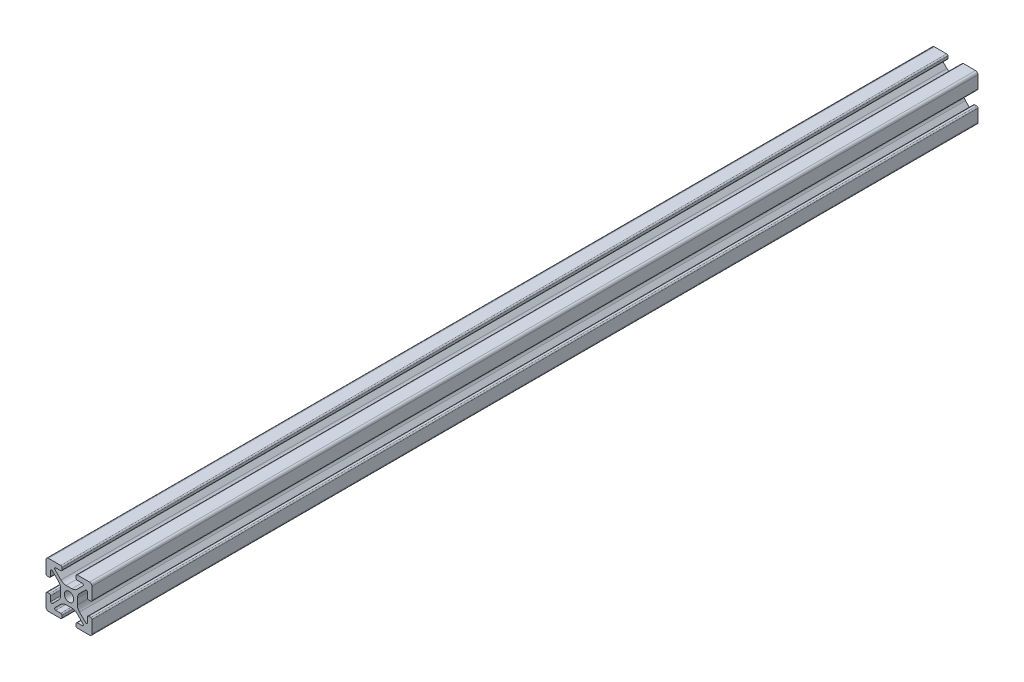
from build123d import *

# Parameters (mm, degrees)
SKETCH2_R           = 2.05
BOSS_EXTRUDE2_DEPTH = 385


with BuildPart() as part:
    # Sketch2 → Boss-Extrude2 (new body)
    with BuildSketch(Plane.XY):
        with BuildLine():
            Line((-3.642230561, 1.287773026), (-3.642230561, -1.287773026))
            ThreePointArc((-3.642230561, -1.287773026), (-3.87999308, -2.483085929), (-4.55708345, -3.496423279))
            Line((-4.55708345, -3.496423279), (-7.182004606, -6.121344434))
            ThreePointArc((-7.182004606, -6.121344434), (-7.704200045, -6.225215565), (-8, -5.782519648))
            Line((-8, -5.782519648), (-8, -3.622007668))
            ThreePointArc((-8, -3.622007668), (-8.161974206, -3.230967343), (-8.553014531, -3.068993137))
            Line((-8.553014531, -3.068993137), (-9.443284204, -3.068993137))
            ThreePointArc((-9.443284204, -3.068993137), (-9.836715763, -3.229656566), (-10, -3.622007668))
            Line((-10, -3.622007668), (-10, -8.939033256))
            ThreePointArc((-10, -8.939033256), (-9.689250035, -9.689250035), (-8.939033256, -10))
            Line((-8.939033256, -10), (-3.622007668, -10))
            ThreePointArc((-3.622007668, -10), (-3.229656566, -9.836715763), (-3.068993137, -9.443284204))
            Line((-3.068993137, -9.443284204), (-3.068993137, -8.553014531))
            ThreePointArc((-3.068993137, -8.553014531), (-3.230967343, -8.161974206), (-3.622007668, -8))
            Line((-3.622007668, -8), (-5.782519648, -8))
            ThreePointArc((-5.782519648, -8), (-6.225215565, -7.704200045), (-6.121344434, -7.182004606))
            Line((-6.121344434, -7.182004606), (-3.496423279, -4.55708345))
            ThreePointArc((-3.496423279, -4.55708345), (-2.483085929, -3.87999308), (-1.287773026, -3.642230561))
            Line((-1.287773026, -3.642230561), (1.287773026, -3.642230561))
            ThreePointArc((1.287773026, -3.642230561), (2.483085929, -3.87999308), (3.496423279, -4.55708345))
            Line((3.496423279, -4.55708345), (6.121344434, -7.182004606))
            ThreePointArc((6.121344434, -7.182004606), (6.225215565, -7.704200045), (5.782519648, -8))
            Line((5.782519648, -8), (3.622007668, -8))
            ThreePointArc((3.622007668, -8), (3.230967343, -8.161974206), (3.068993137, -8.553014531))
            Line((3.068993137, -8.553014531), (3.068993137, -9.443284204))
            ThreePointArc((3.068993137, -9.443284204), (3.229656566, -9.836715763), (3.622007668, -10))
            Line((3.622007668, -10), (8.939033256, -10))
            ThreePointArc((8.939033256, -10), (9.689250035, -9.689250035), (10, -8.939033256))
            Line((10, -8.939033256), (10, -3.622007668))
            ThreePointArc((10, -3.622007668), (9.836715763, -3.229656566), (9.443284204, -3.068993137))
            Line((9.443284204, -3.068993137), (8.553014531, -3.068993137))
            ThreePointArc((8.553014531, -3.068993137), (8.161974206, -3.230967343), (8, -3.622007668))
            Line((8, -3.622007668), (8, -5.782519648))
            ThreePointArc((8, -5.782519648), (7.704200045, -6.225215565), (7.182004606, -6.121344434))
            Line((7.182004606, -6.121344434), (4.55708345, -3.496423279))
            ThreePointArc((4.55708345, -3.496423279), (3.87999308, -2.483085929), (3.642230561, -1.287773026))
            Line((3.642230561, -1.287773026), (3.642230561, 1.287773026))
            ThreePointArc((3.642230561, 1.287773026), (3.87999308, 2.483085929), (4.55708345, 3.496423279))
            Line((4.55708345, 3.496423279), (7.182004606, 6.121344434))
            ThreePointArc((7.182004606, 6.121344434), (7.704200045, 6.225215565), (8, 5.782519648))
            Line((8, 5.782519648), (8, 3.622007668))
            ThreePointArc((8, 3.622007668), (8.161974206, 3.230967343), (8.553014531, 3.068993137))
            Line((8.553014531, 3.068993137), (9.443284204, 3.068993137))
            ThreePointArc((9.443284204, 3.068993137), (9.836715763, 3.229656566), (10, 3.622007668))
            Line((10, 3.622007668), (10, 8.939033256))
            ThreePointArc((10, 8.939033256), (9.689250035, 9.689250035), (8.939033256, 10))
            Line((8.939033256, 10), (3.622007668, 10))
            ThreePointArc((3.622007668, 10), (3.229656566, 9.836715763), (3.068993137, 9.443284204))
            Line((3.068993137, 9.443284204), (3.068993137, 8.553014531))
            ThreePointArc((3.068993137, 8.553014531), (3.230967343, 8.161974206), (3.622007668, 8))
            Line((3.622007668, 8), (5.782519648, 8))
            ThreePointArc((5.782519648, 8), (6.225215565, 7.704200045), (6.121344434, 7.182004606))
            Line((6.121344434, 7.182004606), (3.496423279, 4.55708345))
            ThreePointArc((3.496423279, 4.55708345), (2.483085929, 3.87999308), (1.287773026, 3.642230561))
            Line((1.287773026, 3.642230561), (-1.287773026, 3.642230561))
            ThreePointArc((-1.287773026, 3.642230561), (-2.483085929, 3.87999308), (-3.496423279, 4.55708345))
            Line((-3.496423279, 4.55708345), (-6.121344434, 7.182004606))
            ThreePointArc((-6.121344434, 7.182004606), (-6.225215565, 7.704200045), (-5.782519648, 8))
            Line((-5.782519648, 8), (-3.622007668, 8))
            ThreePointArc((-3.622007668, 8), (-3.230967343, 8.161974206), (-3.068993137, 8.553014531))
            Line((-3.068993137, 8.553014531), (-3.068993137, 9.443284204))
            ThreePointArc((-3.068993137, 9.443284204), (-3.229656566, 9.836715763), (-3.622007668, 10))
            Line((-3.622007668, 10), (-8.939033256, 10))
            ThreePointArc((-8.939033256, 10), (-9.689250035, 9.689250035), (-10, 8.939033256))
            Line((-10, 8.939033256), (-10, 3.622007668))
            ThreePointArc((-10, 3.622007668), (-9.836715763, 3.229656566), (-9.443284204, 3.068993137))
            Line((-9.443284204, 3.068993137), (-8.553014531, 3.068993137))
            ThreePointArc((-8.553014531, 3.068993137), (-8.161974206, 3.230967343), (-8, 3.622007668))
            Line((-8, 3.622007668), (-8, 5.782519648))
            ThreePointArc((-8, 5.782519648), (-7.704200045, 6.225215565), (-7.182004606, 6.121344434))
            Line((-7.182004606, 6.121344434), (-4.55708345, 3.496423279))
            ThreePointArc((-4.55708345, 3.496423279), (-3.87999308, 2.483085929), (-3.642230561, 1.287773026))
        make_face()
        Circle(SKETCH2_R, mode=Mode.SUBTRACT)
    extrude(amount=-BOSS_EXTRUDE2_DEPTH)


solid = part.part
